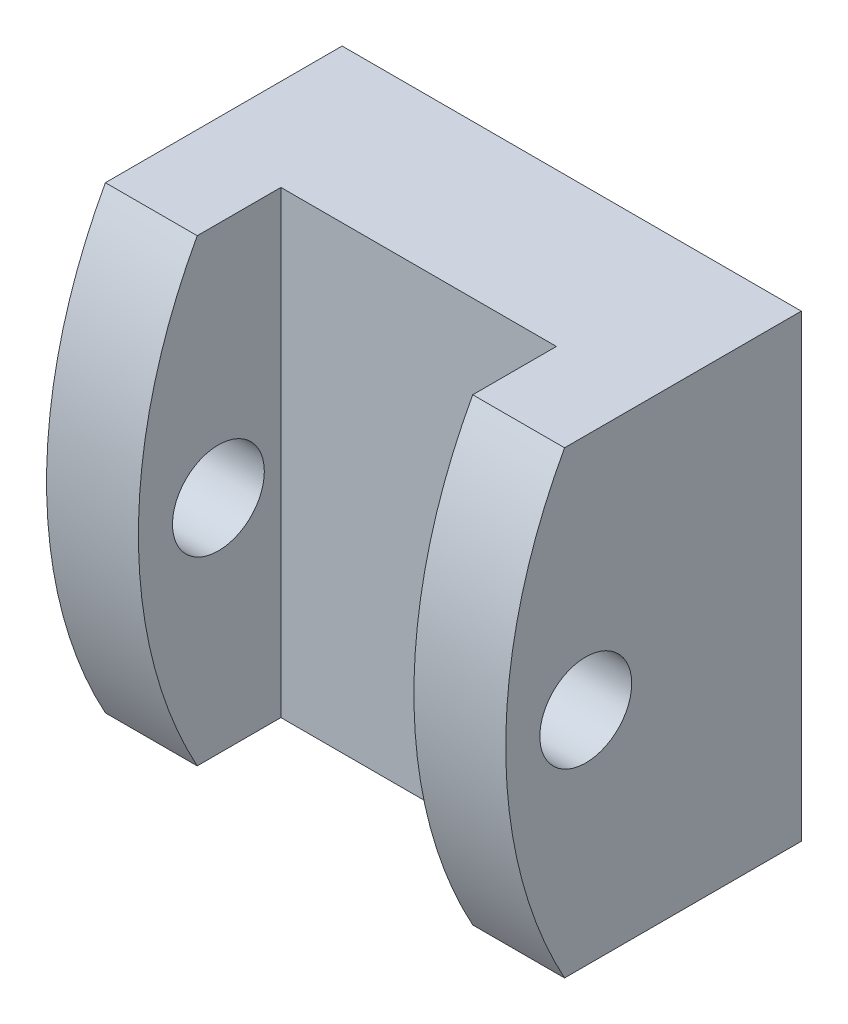
from build123d import *

# Parameters (mm, degrees)
SKETCH1_W               = 15
SKETCH1_H               = 15
BOSS_EXTRUDE1_DEPTH     = 5
SKETCH2_W               = 3
SKETCH2_H               = 15
BOSS_EXTRUDE2_DEPTH     = 5
CUT_EXTRUDE1_DEPTH      = 18
SKETCH4_R               = 1.5
CUT_EXTRUDE2_DEPTH      = 13
CUT_EXTRUDE2_DEPTH_BACK = 4


with BuildPart() as part:
    # Sketch1 → Boss-Extrude1 (new body)
    with BuildSketch(Plane.XY):
        with Locations((-7.5, -7.5)):
            Rectangle(SKETCH1_W, SKETCH1_H)
    extrude(amount=BOSS_EXTRUDE1_DEPTH)

    # Sketch2 → Boss-Extrude2 (add)
    with BuildSketch(Plane.XY.offset(5)):
        with Locations((-1.5, -7.5)):
            Rectangle(SKETCH2_W, SKETCH2_H)
        with Locations((-13.5, -7.5)):
            Rectangle(SKETCH2_W, SKETCH2_H)
    extrude(amount=BOSS_EXTRUDE2_DEPTH)

    # Sketch3 → Cut-Extrude1 (cut)
    with BuildSketch(Plane(origin=(0, 0, 0), x_dir=(0, 0, -1), z_dir=(1, 0, 0))):
        with BuildLine():
            Line((-7.733661886, 0), (-10, 0))
            Line((-10, 0), (-10, -15))
            Line((-10, -15), (-7.733661886, -15))
            ThreePointArc((-7.733661886, -15), (-9.654849758, -7.5), (-7.733661886, 0))
        make_face()
    extrude(amount=-CUT_EXTRUDE1_DEPTH, mode=Mode.SUBTRACT)

    # Sketch4 → Cut-Extrude2 (cut, two sides)
    with BuildSketch(Plane(origin=(-12, 0, 0), x_dir=(0, 0, -1), z_dir=(1, 0, 0))) as cut_extrude2_sk:
        with Locations((-7.041389116, -7.762480296)):
            Circle(SKETCH4_R)
    extrude(amount=CUT_EXTRUDE2_DEPTH, mode=Mode.SUBTRACT)
    extrude(cut_extrude2_sk.sketch, amount=-CUT_EXTRUDE2_DEPTH_BACK, mode=Mode.SUBTRACT)


solid = part.part
